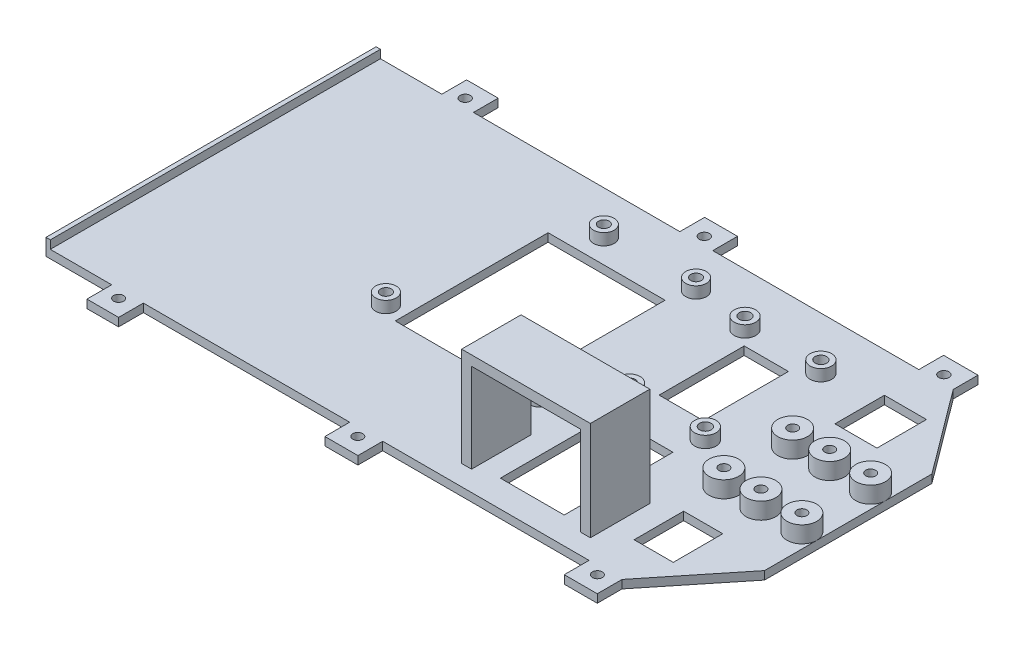
from build123d import *

# Parameters (mm, degrees)
BOSS_EXTRUDE1_DEPTH      = 2.5
SKETCH24_R               = 1.534588162
SKETCH24_R_2             = 1.539679215
SKETCH24_R_3             = 1.53510928
SKETCH24_R_4             = 1.507254119
SKETCH24_R_5             = 1.501766116
SKETCH24_R_6             = 1.506723366
CUT_EXTRUDE7_DEPTH       = 1
CUT_EXTRUDE7_DEPTH_BACK  = 3.5
SKETCH28_R               = 4.5
SKETCH28_R_2             = 1.5
BOSS_EXTRUDE4_DEPTH      = 5
SKETCH29_R               = 1.5
CUT_EXTRUDE10_DEPTH      = 6
CUT_EXTRUDE10_DEPTH_BACK = 3.5
SKETCH30_W               = 39
SKETCH30_H               = 18
BOSS_EXTRUDE5_DEPTH      = 30
CUT_EXTRUDE11_DEPTH      = 32.629888849
SKETCH32_R               = 3.11925
SKETCH32_R_2             = 1.61925
SKETCH32_R_3             = 3.25
SKETCH32_R_4             = 1.75
SKETCH32_R_5             = 3.255054338
SKETCH32_R_6             = 1.755054338
BOSS_EXTRUDE6_DEPTH      = 3.5
SKETCH33_R               = 1.755054338
SKETCH33_R_2             = 1.75
SKETCH33_R_3             = 1.61925
CUT_EXTRUDE12_DEPTH      = 31
CUT_EXTRUDE12_DEPTH_BACK = 3.5
SKETCH34_W               = 35.425074467
SKETCH34_H               = 46.294311582
SKETCH34_W_2             = 13.394736858
SKETCH34_H_2             = 25.79034775
SKETCH34_W_3             = 19.34309219
SKETCH34_H_3             = 32.937244524
SKETCH34_W_4             = 12.732315529
SKETCH34_H_4             = 15
SKETCH34_W_5             = 11.855681534
CUT_EXTRUDE13_DEPTH      = 3.5
SKETCH35_W               = 1.308538477
SKETCH35_H               = 100
BOSS_EXTRUDE7_DEPTH      = 2.5


with BuildPart() as part:
    # Sketch2 → Boss-Extrude1 (new body)
    with BuildSketch(Plane(origin=(0, -17.332299444, 0), x_dir=(-1, 0, 0), z_dir=(0, -1, 0))):
        Polygon((-29.674557938, 41.468970044), (-48.61030302, 16.085172631), (-48.61030302, -34.61356185), (-29.352965282, -58.531029956), (-29.352965282, -66.036105098), (-19.352967368, -66.036105098), (-19.352967368, -58.531029956), (43.147035426, -58.531029956), (43.147035426, -66.036105098), (53.147035202, -66.036105098), (53.147035202, -58.531029956), (115.647037996, -58.531029956), (115.647037996, -66.036105098), (125.241603418, -66.036105098), (125.241603418, -58.531029956), (145.143417646, -58.531029956), (145.143417646, 41.468970044), (125.241603418, 41.468970044), (125.241603418, 48.975336237), (115.668802349, 48.975336237), (115.668802349, 41.468970044), (53.135946408, 41.468970044), (53.135946408, 48.975336237), (43.168799778, 48.975336237), (43.168799778, 41.468970044), (-19.254443916, 41.468970044), (-19.254443916, 48.975336237), (-29.674557938, 48.975336237), align=None)
    extrude(amount=-BOSS_EXTRUDE1_DEPTH)

    # Sketch24 → Cut-Extrude7 (cut, two sides)
    with BuildSketch(Plane(origin=(0, -14.832299444, 0), x_dir=(1, 0, 0), z_dir=(0, 1, 0))) as cut_extrude7_sk:
        with Locations((-120.631514326, 43.936289371)):
            Circle(SKETCH24_R)
        with Locations((-48.193182725, 43.936289371)):
            Circle(SKETCH24_R_2)
        with Locations((24.374871647, 43.936289371)):
            Circle(SKETCH24_R_3)
        with Locations((24.374871647, -61.035755979)):
            Circle(SKETCH24_R_4)
        with Locations((-48.193182725, -61.035755979)):
            Circle(SKETCH24_R_5)
        with Locations((-120.631514326, -61.035755979)):
            Circle(SKETCH24_R_6)
    extrude(amount=CUT_EXTRUDE7_DEPTH, mode=Mode.SUBTRACT)
    extrude(cut_extrude7_sk.sketch, amount=-CUT_EXTRUDE7_DEPTH_BACK, mode=Mode.SUBTRACT)

    # Sketch28 → Boss-Extrude4 (add)
    with BuildSketch(Plane(origin=(0, -14.832299444, 0), x_dir=(1, 0, 0), z_dir=(0, 1, 0))):
        with Locations((44.095100387, -18.794047136)):
            Circle(SKETCH28_R)
        with Locations((44.095100387, -18.794047136)):
            Circle(SKETCH28_R_2, mode=Mode.SUBTRACT)
        with Locations((44.095100387, 2.033952864)):
            Circle(SKETCH28_R)
        with Locations((44.095100387, 2.033952864)):
            Circle(SKETCH28_R_2, mode=Mode.SUBTRACT)
        with Locations((31.687794159, 2.033952864)):
            Circle(SKETCH28_R)
        with Locations((31.687794159, 2.033952864)):
            Circle(SKETCH28_R_2, mode=Mode.SUBTRACT)
        with Locations((31.687794159, -18.794047136)):
            Circle(SKETCH28_R)
        with Locations((31.687794159, -18.794047136)):
            Circle(SKETCH28_R_2, mode=Mode.SUBTRACT)
        with Locations((20.460418505, 2.033952864)):
            Circle(SKETCH28_R)
        with Locations((20.460418505, 2.033952864)):
            Circle(SKETCH28_R_2, mode=Mode.SUBTRACT)
        with Locations((20.460418505, -18.794047136)):
            Circle(SKETCH28_R)
        with Locations((20.460418505, -18.794047136)):
            Circle(SKETCH28_R_2, mode=Mode.SUBTRACT)
    extrude(amount=BOSS_EXTRUDE4_DEPTH)

    # Sketch29 → Cut-Extrude10 (cut, two sides)
    with BuildSketch(Plane(origin=(0, -14.832299444, 0), x_dir=(1, 0, 0), z_dir=(0, 1, 0))) as cut_extrude10_sk:
        with Locations((44.095100387, -18.794047136)):
            Circle(SKETCH29_R)
        with Locations((44.095100387, 2.033952864)):
            Circle(SKETCH29_R)
        with Locations((20.460418505, -18.794047136)):
            Circle(SKETCH29_R)
        with Locations((20.460418505, 2.033952864)):
            Circle(SKETCH29_R)
        with Locations((31.687794159, 2.033952864)):
            Circle(SKETCH29_R)
        with Locations((31.687794159, -18.794047136)):
            Circle(SKETCH29_R)
    extrude(amount=CUT_EXTRUDE10_DEPTH, mode=Mode.SUBTRACT)
    extrude(cut_extrude10_sk.sketch, amount=-CUT_EXTRUDE10_DEPTH_BACK, mode=Mode.SUBTRACT)

    # Sketch30 → Boss-Extrude5 (add)
    with BuildSketch(Plane(origin=(0, -14.832299444, 0), x_dir=(1, 0, 0), z_dir=(0, 1, 0))):
        with Locations((-5.862319178, -43.406216249)):
            Rectangle(SKETCH30_W, SKETCH30_H)
    extrude(amount=BOSS_EXTRUDE5_DEPTH)

    # Sketch31 → Cut-Extrude11 (cut, through all)
    with BuildSketch(Plane(origin=(0, 0, 34.406216249), x_dir=(-1, 0, 0), z_dir=(0, 0, -1))):
        Polygon((-10.637680822, -11.832299444), (-10.637680822, -14.832299444), (22.362319178, -14.832299444), (22.362319178, -11.832299444), (22.362319178, 12.167700556), (-10.637680822, 12.167700556), align=None)
    extrude(amount=-CUT_EXTRUDE11_DEPTH, mode=Mode.SUBTRACT)

    # Sketch32 → Boss-Extrude6 (add)
    with BuildSketch(Plane(origin=(0, -14.832299444, 0), x_dir=(1, 0, 0), z_dir=(0, 1, 0))):
        with Locations((-78.332170896, -22.386024774)):
            Circle(SKETCH32_R)
        with Locations((-78.332170896, -22.386024774)):
            Circle(SKETCH32_R_2, mode=Mode.SUBTRACT)
        with Locations((-63.092170896, 28.401275226)):
            Circle(SKETCH32_R)
        with Locations((-63.092170896, 28.401275226)):
            Circle(SKETCH32_R_2, mode=Mode.SUBTRACT)
        with Locations((-35.164870896, 28.401275226)):
            Circle(SKETCH32_R)
        with Locations((-35.164870896, 28.401275226)):
            Circle(SKETCH32_R_2, mode=Mode.SUBTRACT)
        with Locations((-30.415070896, -23.529024774)):
            Circle(SKETCH32_R)
        with Locations((-30.415070896, -23.529024774)):
            Circle(SKETCH32_R_2, mode=Mode.SUBTRACT)
        with Locations((5.365042011, 25.69595377)):
            Circle(SKETCH32_R_3)
        with Locations((5.365042011, 25.69595377)):
            Circle(SKETCH32_R_4, mode=Mode.SUBTRACT)
        with Locations((5.365042011, -9.30404623)):
            Circle(SKETCH32_R_3)
        with Locations((5.365042011, -9.30404623)):
            Circle(SKETCH32_R_4, mode=Mode.SUBTRACT)
        with Locations((-17.634957989, -9.30404623)):
            Circle(SKETCH32_R_5)
        with Locations((-17.634957989, -9.30404623)):
            Circle(SKETCH32_R_6, mode=Mode.SUBTRACT)
        with Locations((-17.634957989, 25.69595377)):
            Circle(SKETCH32_R_5)
        with Locations((-17.634957989, 25.69595377)):
            Circle(SKETCH32_R_6, mode=Mode.SUBTRACT)
    extrude(amount=BOSS_EXTRUDE6_DEPTH)

    # Sketch33 → Cut-Extrude12 (cut, two sides)
    with BuildSketch(Plane(origin=(0, -14.832299444, 0), x_dir=(1, 0, 0), z_dir=(0, 1, 0))) as cut_extrude12_sk:
        with Locations((-17.634957989, 25.69595377)):
            Circle(SKETCH33_R)
        with Locations((-17.634957989, -9.30404623)):
            Circle(SKETCH33_R)
        with Locations((5.365042011, -9.30404623)):
            Circle(SKETCH33_R_2)
        with Locations((5.365042011, 25.69595377)):
            Circle(SKETCH33_R_2)
        with Locations((-78.332170896, -22.386024774)):
            Circle(SKETCH33_R_3)
        with Locations((-63.092170896, 28.401275226)):
            Circle(SKETCH33_R_3)
        with Locations((-35.164870896, 28.401275226)):
            Circle(SKETCH33_R_3)
        with Locations((-30.415070896, -23.529024774)):
            Circle(SKETCH33_R_3)
    extrude(amount=CUT_EXTRUDE12_DEPTH, mode=Mode.SUBTRACT)
    extrude(cut_extrude12_sk.sketch, amount=-CUT_EXTRUDE12_DEPTH_BACK, mode=Mode.SUBTRACT)

    # Sketch34 → Cut-Extrude13 (cut, through all)
    with BuildSketch(Plane(origin=(0, -14.832299444, 0), x_dir=(1, 0, 0), z_dir=(0, 1, 0))):
        with Locations((-55.089850794, -1.917647795)):
            Rectangle(SKETCH34_W, SKETCH34_H)
        with Locations((-6.697368429, 8.334334121)):
            Rectangle(SKETCH34_W_2, SKETCH34_H_2)
        with Locations((-5.977817897, -33.923153054)):
            Rectangle(SKETCH34_W_3, SKETCH34_H_3)
        with Locations((27.139734393, 22.033952864)):
            Rectangle(SKETCH34_W_4, SKETCH34_H_4)
        with Locations((26.701417396, -38.794047136)):
            Rectangle(SKETCH34_W_5, SKETCH34_H_4)
    extrude(amount=-CUT_EXTRUDE13_DEPTH, mode=Mode.SUBTRACT)

    # Sketch35 → Boss-Extrude7 (add)
    with BuildSketch(Plane(origin=(0, -14.832299444, 0), x_dir=(1, 0, 0), z_dir=(0, 1, 0))):
        with Locations((-144.489148408, -8.531029956)):
            Rectangle(SKETCH35_W, SKETCH35_H)
    extrude(amount=BOSS_EXTRUDE7_DEPTH)


solid = part.part
